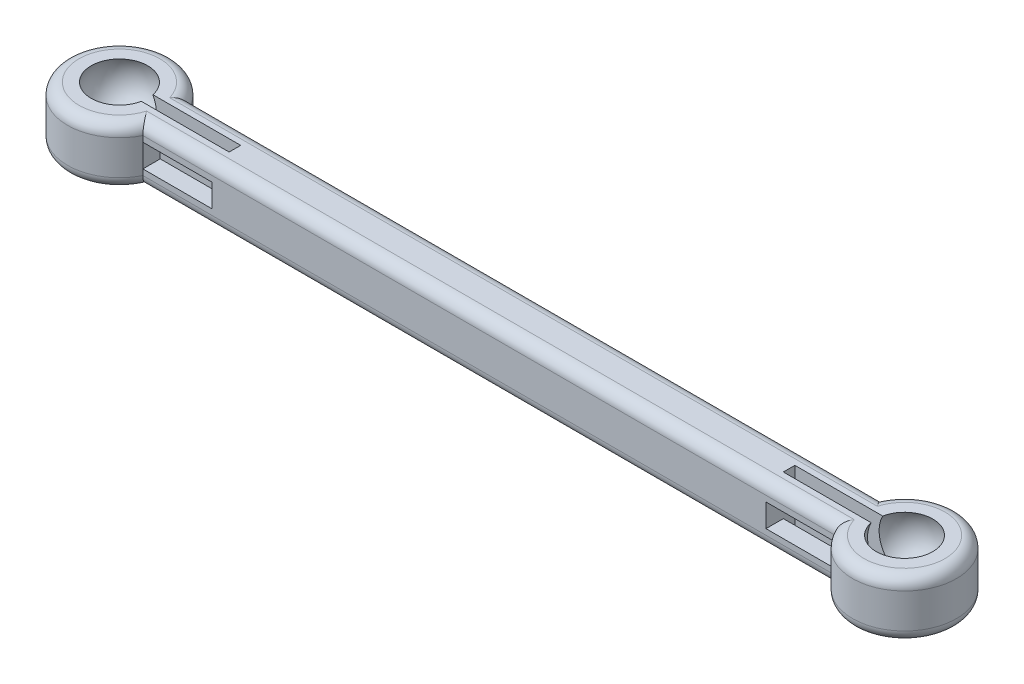
from build123d import *

# Parameters (mm, degrees)
BOSS_EXTRUDE1_DEPTH = 5
CUT_EXTRUDE1_REACH  = 41.083
CUT_EXTRUDE2_REACH  = 41.364
FILLET1_R           = 1


with BuildPart() as part:
    # Sketch1 → Boss-Extrude1 (new body)
    with BuildSketch(Plane(origin=(0, 0, 0), x_dir=(1, 0, 0), z_dir=(0, 1, 0))):
        with BuildLine():
            Line((-33.99999999999999, 2), (-33.99999999999999, -2))
            Line((-33.99999999999999, -2), (-29.968871125850622, -2))
            ThreePointArc((-29.968871125850665, -1.9999999999998734), (-29.618785560277153, -1.0271124734730797), (-29.5, -1.1e-15))
            ThreePointArc((-29.5, 0), (-29.618785560277153, 1.0271124734730805), (-29.968871125850665, 1.9999999999998725))
            Line((-29.968871125850622, 2), (-33.99999999999999, 2))
        make_face()
        with BuildLine():
            Line((-29.968871125850622, -2), (-33.99999999999999, -2))
            Line((-33.99999999999999, -2), (-33.99999999999999, 2))
            Line((-33.99999999999999, 2), (-29.968871125850622, 2))
            ThreePointArc((-29.968871125850665, 1.9999999999998725), (-38.499999999999986, 5.5e-16), (-29.968871125850665, -1.9999999999998734))
        make_face()
        with BuildLine():
            ThreePointArc((-29.5, -1.1e-15), (-29.618785560277153, -1.0271124734730797), (-29.968871125850665, -1.9999999999998734))
            Line((-29.968871125850622, -2), (29.96887112585072, -2))
            ThreePointArc((29.96887112585073, -1.9999999999999722), (29.500000000000014, 5.5e-16), (29.96887112585073, 1.9999999999999731))
            Line((29.96887112585072, 2), (-29.968871125850622, 2))
            ThreePointArc((-29.968871125850665, 1.9999999999998725), (-29.618785560277153, 1.0271124734730805), (-29.5, 0))
        make_face()
        with BuildLine():
            ThreePointArc((29.96887112585073, 1.9999999999999731), (29.500000000000014, 5.5e-16), (29.96887112585073, -1.9999999999999722))
            Line((29.96887112585072, -2), (34.00000000000001, -2))
            Line((34.00000000000001, -2), (34.00000000000001, 2))
            Line((34.00000000000001, 2), (29.96887112585072, 2))
        make_face()
        with BuildLine():
            Line((34.00000000000001, -2), (29.96887112585072, -2))
            ThreePointArc((29.96887112585073, -1.9999999999999722), (35.02711247347314, -4.38121443972283), (38.5, -1.1e-15))
            ThreePointArc((38.5, 0), (35.02711247347314, 4.381214439722829), (29.96887112585073, 1.9999999999999731))
            Line((29.96887112585072, 2), (34.00000000000001, 2))
            Line((34.00000000000001, 2), (34.00000000000001, -2))
        make_face()
    extrude(amount=BOSS_EXTRUDE1_DEPTH)

    # Cut-Sweep1: sweep along a path in Sketch2
    with BuildLine(Plane(origin=(0, 5, 0), x_dir=(1, 0, 0), z_dir=(0, 1, 0))) as cut_sweep1_path:
        CenterArc((-33.99999999999999, 0), 4.499999999999991, 0, 360)
    # 3DSketch1 → Cut-Sweep1 (sweep, cut)
    with BuildSketch(Plane(origin=(-33.99999999999999, 5, 0), x_dir=(0, -1, 0), z_dir=(-1, 0, 0))):
        with BuildLine():
            Line((0, 0), (-1.5000000000000004, 0))
            ThreePointArc((-1.5000000000000004, 0), (1.25, 2.75), (4, 0))
            Line((4, 0), (0, 0))
        make_face()
    cut_sweep1 = sweep(path=cut_sweep1_path.line, mode=Mode.SUBTRACT)

    # Mirror1: Cut-Sweep1 across plane
    add(cut_sweep1.mirror(Plane(origin=(0, 0, 0), x_dir=(0, 0, 1), z_dir=(1, 0, 0))), mode=Mode.SUBTRACT)

    # Cut-Extrude1: up to this face of the body (flat: up to its plane)
    cut_extrude1_end = Plane(part.part.faces().sort_by_distance((0, 5, -2.639e-06))[0])
    # Sketch3 → Cut-Extrude1 (cut, up to the picked face)
    with BuildSketch(Plane.XZ, mode=Mode.PRIVATE) as cut_extrude1_sk1:
        with BuildLine():
            ThreePointArc((-29.52786404500042, 0.49999999999997785), (-29.506971411314076, 0.2503879015666308), (-29.5, 0))
            Line((-29.5, 0), (-23.999999999999993, 0))
            Line((-23.999999999999993, 0), (-23.999999999999993, 0.5))
            Line((-23.999999999999993, 0.5), (-29.527864045000417, 0.5))
        make_face()
    cut_extrude1_tool1 = split(extrude(cut_extrude1_sk1.sketch, amount=-CUT_EXTRUDE1_REACH, mode=Mode.PRIVATE), bisect_by=cut_extrude1_end, keep=Keep.BOTH, mode=Mode.PRIVATE)
    # Sketch3 → Cut-Extrude1 (cut, up to the picked face)
    with BuildSketch(Plane.XZ, mode=Mode.PRIVATE) as cut_extrude1_sk2:
        with BuildLine():
            Line((-23.999999999999993, 0), (-29.5, 0))
            ThreePointArc((-29.5, -1.1e-15), (-29.506971411314076, -0.25038790156662954), (-29.52786404500042, -0.49999999999997824))
            Line((-29.527864045000417, -0.5), (-23.999999999999993, -0.5))
            Line((-23.999999999999993, -0.5), (-23.999999999999993, 0))
        make_face()
    cut_extrude1_tool2 = split(extrude(cut_extrude1_sk2.sketch, amount=-CUT_EXTRUDE1_REACH, mode=Mode.PRIVATE), bisect_by=cut_extrude1_end, keep=Keep.BOTH, mode=Mode.PRIVATE)
    # Sketch3 → Cut-Extrude1 (cut, up to the picked face)
    with BuildSketch(Plane.XZ, mode=Mode.PRIVATE) as cut_extrude1_sk3:
        with BuildLine():
            Line((-33.99999999999999, 0.5), (-33.99999999999999, 0))
            Line((-33.99999999999999, 0), (-29.5, 0))
            ThreePointArc((-29.5, 0), (-29.506971411314076, 0.2503879015666308), (-29.52786404500042, 0.49999999999997785))
            Line((-29.527864045000417, 0.5), (-33.99999999999999, 0.5))
        make_face()
    cut_extrude1_tool3 = split(extrude(cut_extrude1_sk3.sketch, amount=-CUT_EXTRUDE1_REACH, mode=Mode.PRIVATE), bisect_by=cut_extrude1_end, keep=Keep.BOTH, mode=Mode.PRIVATE)
    # Sketch3 → Cut-Extrude1 (cut, up to the picked face)
    with BuildSketch(Plane.XZ, mode=Mode.PRIVATE) as cut_extrude1_sk4:
        with BuildLine():
            Line((-29.5, 0), (-33.99999999999999, 0))
            Line((-33.99999999999999, 0), (-33.99999999999999, -0.5))
            Line((-33.99999999999999, -0.5), (-29.527864045000417, -0.5))
            ThreePointArc((-29.52786404500042, -0.49999999999997824), (-29.506971411314076, -0.25038790156662954), (-29.5, -1.1e-15))
        make_face()
    cut_extrude1_tool4 = split(extrude(cut_extrude1_sk4.sketch, amount=-CUT_EXTRUDE1_REACH, mode=Mode.PRIVATE), bisect_by=cut_extrude1_end, keep=Keep.BOTH, mode=Mode.PRIVATE)
    cut_extrude1_1 = cut_extrude1_tool1.solids().sort_by(Axis((-26.754644, 0, 0.250211), (0, 1, 0)))[0]
    add(cut_extrude1_1, mode=Mode.SUBTRACT)
    cut_extrude1_2 = cut_extrude1_tool2.solids().sort_by(Axis((-26.754644, 0, -0.250211), (0, 1, 0)))[0]
    add(cut_extrude1_2, mode=Mode.SUBTRACT)
    cut_extrude1_3 = cut_extrude1_tool3.solids().sort_by(Axis((-31.754631, 0, 0.249742), (0, 1, 0)))[0]
    add(cut_extrude1_3, mode=Mode.SUBTRACT)
    cut_extrude1_4 = cut_extrude1_tool4.solids().sort_by(Axis((-31.754631, 0, -0.249742), (0, 1, 0)))[0]
    add(cut_extrude1_4, mode=Mode.SUBTRACT)
    cut_extrude1 = cut_extrude1_1 + cut_extrude1_2 + cut_extrude1_3 + cut_extrude1_4  # Cut-Extrude1 as one shape, for the pattern or mirror that repeats it

    # Mirror2: Cut-Extrude1 across plane
    add(cut_extrude1.mirror(Plane(origin=(0, 0, 0), x_dir=(0, 0, 1), z_dir=(1, 0, 0))), mode=Mode.SUBTRACT)

    # Cut-Extrude2: up to this face of the body (flat: up to its plane)
    cut_extrude2_end = Plane(part.part.faces().sort_by_distance((0, 2.5, 2))[0])
    # Sketch4 → Cut-Extrude2 (cut, up to the picked face)
    with BuildSketch(Plane(origin=(0, 0, -2), x_dir=(-1, 0, 0), z_dir=(0, 0, -1)), mode=Mode.PRIVATE) as cut_extrude2_sk1:
        Polygon((23.99999999999999, 1.5000000000000009), (28.178209788095508, 1.5000000000000009), (25.790661337755214, 3.5000000000000004), (23.99999999999999, 3.500000000000001), align=None)
    cut_extrude2_tool1 = split(extrude(cut_extrude2_sk1.sketch, amount=-CUT_EXTRUDE2_REACH, mode=Mode.PRIVATE), bisect_by=cut_extrude2_end, keep=Keep.BOTH, mode=Mode.PRIVATE)
    # Sketch4 → Cut-Extrude2 (cut, up to the picked face)
    with BuildSketch(Plane(origin=(0, 0, -2), x_dir=(-1, 0, 0), z_dir=(0, 0, -1)), mode=Mode.PRIVATE) as cut_extrude2_sk2:
        Polygon((25.790661337755214, 3.5000000000000004), (28.178209788095508, 1.5000000000000007), (29.96887112585073, 1.5000000000000009), (29.96887112585073, 3.500000000000001), align=None)
    cut_extrude2_tool2 = split(extrude(cut_extrude2_sk2.sketch, amount=-CUT_EXTRUDE2_REACH, mode=Mode.PRIVATE), bisect_by=cut_extrude2_end, keep=Keep.BOTH, mode=Mode.PRIVATE)
    cut_extrude2_1 = cut_extrude2_tool1.solids().sort_by(Axis((-25.571803, 2.366667, -2), (0, 0, 1)))[0]
    add(cut_extrude2_1, mode=Mode.SUBTRACT)
    cut_extrude2_2 = cut_extrude2_tool2.solids().sort_by(Axis((-28.397068, 2.633333, -2), (0, 0, 1)))[0]
    add(cut_extrude2_2, mode=Mode.SUBTRACT)
    cut_extrude2 = cut_extrude2_1 + cut_extrude2_2  # Cut-Extrude2 as one shape, for the pattern or mirror that repeats it

    # Mirror3: Cut-Extrude2 across plane
    add(cut_extrude2.mirror(Plane(origin=(0, 0, 0), x_dir=(0, 0, 1), z_dir=(1, 0, 0))), mode=Mode.SUBTRACT)

    # Fillet1
    fillet1_edges = [part.edges().sort_by_distance(p)[0] for p in [
        (3.908e-14, 5, 1.9999999999999665),
        (38.5, 5, 4.44e-15),
        (3.553e-14, 5, -1.999999999999966),
        (-38.50000000000023, 5, 5.89e-14),
        (3.553e-14, 0, -1.999999999999966),
        (38.5, 0, -2e-15),
        (3.908e-14, 0, 1.9999999999999665),
        (-38.50000000000024, 0, -6.573e-14),
    ]]
    fillet(fillet1_edges, radius=FILLET1_R)


solid = part.part
